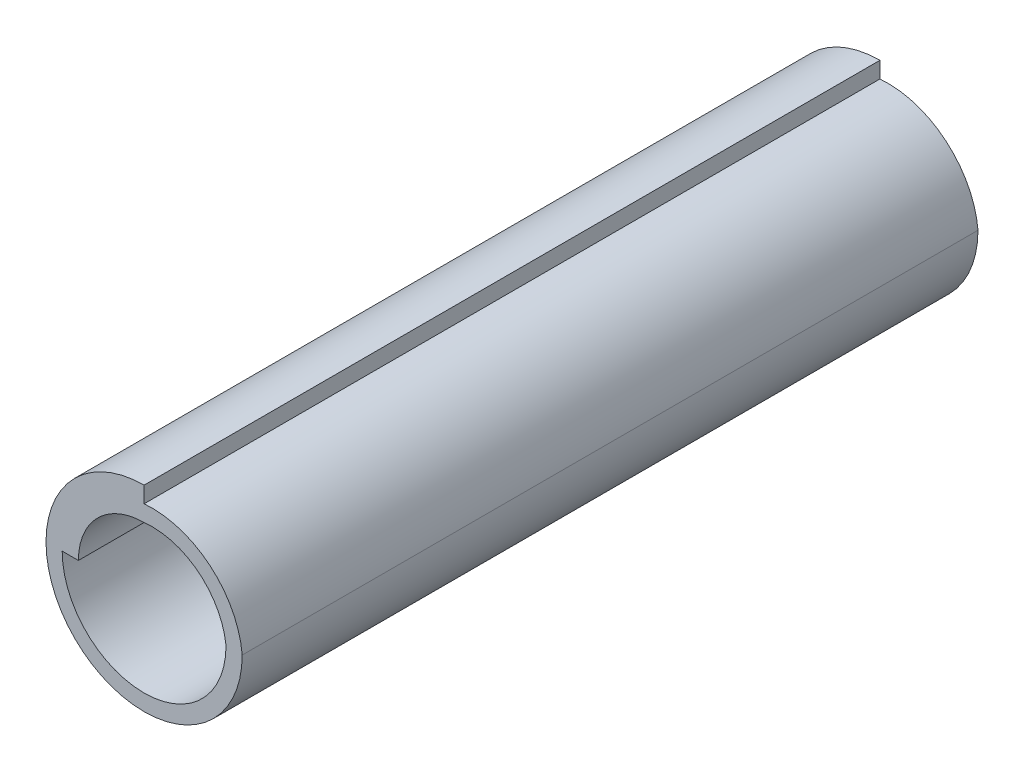
from build123d import *

# Parameters (mm, degrees)
BASE_EXTRUDE_DEPTH = 7.5


with BuildPart() as part:
    # Sketch1 → Base-Extrude (new body, symmetric)
    with BuildSketch(Plane.XY):
        with BuildLine():
            Line((0, 1.67), (0, 2))
            ThreePointArc((0, 2), (-1.414213562, -1.414213562), (2, 0))
            ThreePointArc((2, 0), (1.345868325, 1.249213562), (0, 1.67))
        make_face()
        with BuildLine():
            Line((-1.67, 0), (-1.34, 0))
            ThreePointArc((-1.34, 0), (-0.947523087, 0.947523087), (0, 1.34))
            ThreePointArc((0, 1.34), (1.112523087, 1.015868325), (1.67, 0))
            ThreePointArc((1.67, 0), (0, -1.67), (-1.67, 0))
        make_face(mode=Mode.SUBTRACT)
    extrude(amount=BASE_EXTRUDE_DEPTH, both=True)


solid = part.part
